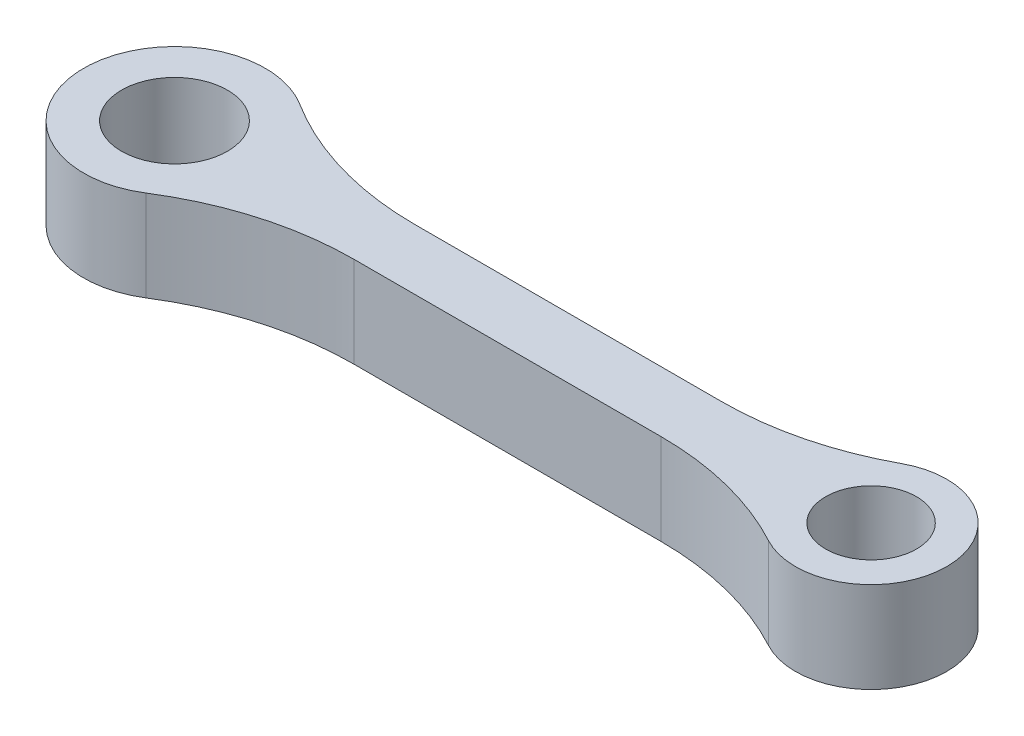
from build123d import *

# Parameters (mm, degrees)
SKETCH1_R           = 1.75
SKETCH1_R_2         = 1.5
BOSS_EXTRUDE1_DEPTH = 3


with BuildPart() as part:
    # Sketch1 → Boss-Extrude1 (new body)
    with BuildSketch(Plane(origin=(0, 0, 0), x_dir=(1, 0, 0), z_dir=(0, 1, 0))):
        with BuildLine():
            Line((6.92820323, 1), (17.062828956, 1))
            ThreePointArc((17.062828956, 1), (19.512318699, 1.304640285), (21.812565791, 2.2))
            ThreePointArc((21.812565791, 2.2), (25.5, 0), (21.812565791, -2.2))
            ThreePointArc((21.812565791, -2.2), (19.512318699, -1.304640285), (17.062828956, -1))
            Line((17.062828956, -1), (6.92820323, -1))
            ThreePointArc((6.92820323, -1), (4.154702249, -1.392310772), (1.59881613, -2.538461538))
            ThreePointArc((1.59881613, -2.538461538), (-3, 0), (1.59881613, 2.538461538))
            ThreePointArc((1.59881613, 2.538461538), (4.154702249, 1.392310772), (6.92820323, 1))
        make_face()
        Circle(SKETCH1_R, mode=Mode.SUBTRACT)
        with Locations((23, 0)):
            Circle(SKETCH1_R_2, mode=Mode.SUBTRACT)
    extrude(amount=BOSS_EXTRUDE1_DEPTH)


solid = part.part
